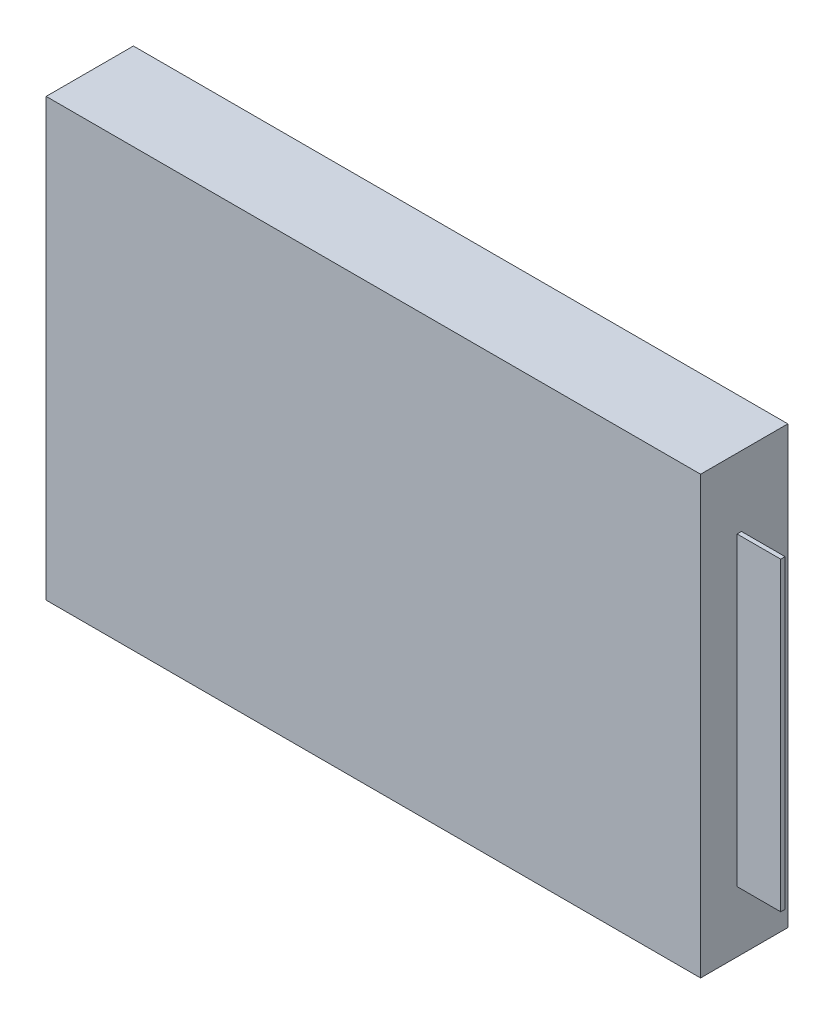
from build123d import *

# Parameters (mm, degrees)
SKETCH1_W           = 30
SKETCH1_H           = 20
BOSS_EXTRUDE2_DEPTH = 4
SKETCH2_W           = 0.2
SKETCH2_H           = 14
BOSS_EXTRUDE4_DEPTH = 2


with BuildPart() as part:
    # Sketch1 → Boss-Extrude2 (new body)
    with BuildSketch(Plane.XY):
        Rectangle(SKETCH1_W, SKETCH1_H)
    extrude(amount=BOSS_EXTRUDE2_DEPTH)

    # Sketch2 → Boss-Extrude4 (add)
    with BuildSketch(Plane(origin=(15, 0, 0), x_dir=(0, 0, -1), z_dir=(1, 0, 0))):
        with Locations((-2.225414416, -0.209852037)):
            Rectangle(SKETCH2_W, SKETCH2_H)
    extrude(amount=BOSS_EXTRUDE4_DEPTH)


solid = part.part
